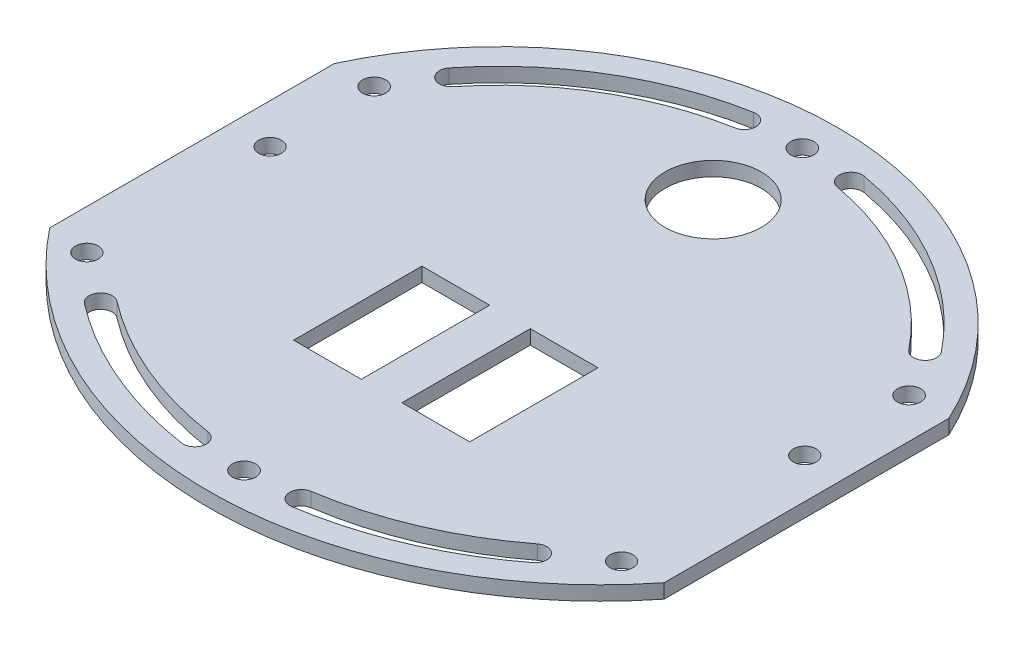
from build123d import *

# Parameters (mm, degrees)
BOSS_EXTRUDE1_DEPTH     = 2
SKETCH2_R               = 3.2
SKETCH2_R_2             = 3.25
CUT_HOLES_DEPTH         = 3
CUT_HOLES_DEPTH_BACK    = 3
SKETCH3_R               = 13.5
SKETCH3_W               = 19
SKETCH3_H               = 36
CUT_EXTRUDE2_DEPTH      = 3
CUT_EXTRUDE2_DEPTH_BACK = 3


with BuildPart() as part:
    # Sketch1 → Boss-Extrude1 (new body, symmetric)
    with BuildSketch(Plane(origin=(0, 0, 0), x_dir=(1, 0, 0), z_dir=(0, 1, 0))):
        with BuildLine():
            Line((86.2, 39.931942102), (86.2, -39.931942102))
            ThreePointArc((86.2, -39.931942102), (0, -81.597763245), (-86.2, -39.931942102))
            Line((-86.2, -39.931942102), (-86.2, 39.931942102))
            ThreePointArc((-86.2, 39.931942102), (0, 95), (86.2, 39.931942102))
        make_face()
    extrude(amount=BOSS_EXTRUDE1_DEPTH, both=True)

    # Sketch2 → Cut-Holes (cut, two sides)
    with BuildSketch(Plane(origin=(0, 0, 0), x_dir=(1, 0, 0), z_dir=(0, 1, 0))) as cut_holes_sk:
        with Locations((-75, 10.7)):
            Circle(SKETCH2_R)
        with Locations((-75, -40.7)):
            Circle(SKETCH2_R)
        with Locations((75, -40.7)):
            Circle(SKETCH2_R)
        with Locations((75, 10.7)):
            Circle(SKETCH2_R)
        with Locations((0, -71.597763245)):
            Circle(SKETCH2_R_2)
        with Locations((0, 85)):
            Circle(SKETCH2_R_2)
        with Locations((-75.036257902, 39.931942102)):
            Circle(SKETCH2_R_2)
        with Locations((75.036257902, 39.931942102)):
            Circle(SKETCH2_R_2)
        with BuildLine():
            ThreePointArc((14.471626034, -67.259325745), (11.744315506, -70.958890218), (15.443879979, -73.686200745))
            ThreePointArc((15.443879979, -73.686200745), (40.475581865, -66.58349782), (62.936747266, -53.448409812))
            ThreePointArc((62.936747266, -53.448409812), (63.532100029, -48.890937367), (58.974627584, -48.295584605))
            ThreePointArc((58.974627584, -48.295584605), (37.92748228, -60.603766345), (14.471626034, -67.259325745))
        make_face()
        with BuildLine():
            ThreePointArc((-62.936747266, -53.448409812), (-63.532100029, -48.890937367), (-58.974627584, -48.295584605))
            ThreePointArc((-58.974627584, -48.295584605), (-37.92748228, -60.603766345), (-14.471626034, -67.259325745))
            ThreePointArc((-14.471626034, -67.259325745), (-11.744315506, -70.958890218), (-15.443879979, -73.686200745))
            ThreePointArc((-15.443879979, -73.686200745), (-40.475581865, -66.58349782), (-62.936747266, -53.448409812))
        make_face()
        with BuildLine():
            ThreePointArc((-63.94162293, 50.936542452), (-68.508644796, 50.419520904), (-69.025666344, 54.98654277))
            ThreePointArc((-69.025666344, 54.98654277), (-45.1765399, 75.809911903), (-15.512787354, 86.875865052))
            ThreePointArc((-15.512787354, 86.875865052), (-11.742100438, 84.24776304), (-14.37020245, 80.477076125))
            ThreePointArc((-14.37020245, 80.477076125), (-41.849089369, 70.226179015), (-63.94162293, 50.936542452))
        make_face()
        with BuildLine():
            ThreePointArc((15.512787354, 86.875865052), (11.742100438, 84.24776304), (14.37020245, 80.477076125))
            ThreePointArc((14.37020245, 80.477076125), (41.849089369, 70.226179015), (63.94162293, 50.936542452))
            ThreePointArc((63.94162293, 50.936542452), (68.508644796, 50.419520904), (69.025666344, 54.98654277))
            ThreePointArc((69.025666344, 54.98654277), (45.1765399, 75.809911903), (15.512787354, 86.875865052))
        make_face()
    extrude(amount=CUT_HOLES_DEPTH, mode=Mode.SUBTRACT)
    extrude(cut_holes_sk.sketch, amount=-CUT_HOLES_DEPTH_BACK, mode=Mode.SUBTRACT)

    # Sketch3 → Cut-Extrude2 (cut, two sides)
    with BuildSketch(Plane(origin=(0, 0, 0), x_dir=(1, 0, 0), z_dir=(0, 1, 0))) as cut_extrude2_sk:
        with Locations((0, 60)):
            Circle(SKETCH3_R)
        with Locations((-15.2, -15)):
            Rectangle(SKETCH3_W, SKETCH3_H)
        with Locations((15.2, -15)):
            Rectangle(SKETCH3_W, SKETCH3_H)
    extrude(amount=CUT_EXTRUDE2_DEPTH, mode=Mode.SUBTRACT)
    extrude(cut_extrude2_sk.sketch, amount=-CUT_EXTRUDE2_DEPTH_BACK, mode=Mode.SUBTRACT)


solid = part.part
